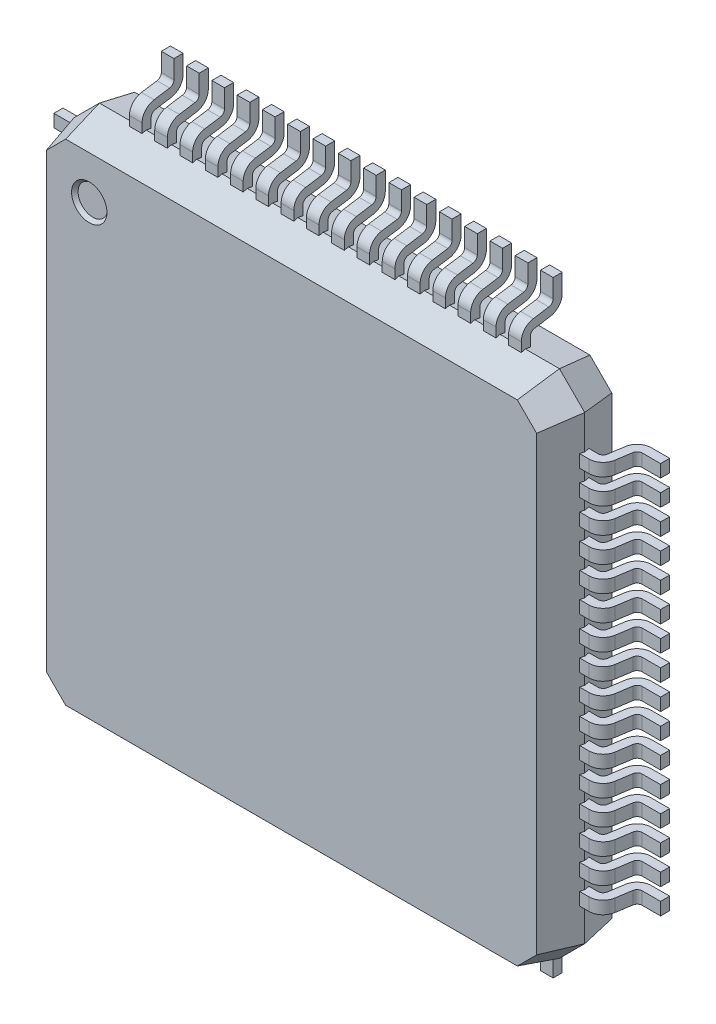
from build123d import *

# Parameters (mm, degrees)
EXTRUDE_START                    = 0.75
EXTRUDE_1_DEPTH                  = 0.75
EXTRUDE_1_TAPER                  = 15
EXTRUDE_1_OTHER_WAY_DEPTH        = 0.65
EXTRUDE_1_OTHER_WAY_TAPER        = 10
EXTRUDE_START_2                  = 3.875
EXTRUDE_2_DEPTH                  = 0.25
EXTRUDE_2_2_DEPTH                = 0.25
SKETCH_2_R                       = 0.35
CUT_EXTRUDE_3_DEPTH              = 0.07
CUT_EXTRUDE_3_TAPER              = 40
PATTERN_LINEAR_1_COUNT           = 16
PATTERN_LINEAR_1_PITCH           = 0.5
PATTERN_CIRCULAR_1_COUNT         = 2
PATTERN_CIRCULAR_1_ANGLE         = 90
PATTERN_START                    = 3.875
PATTERN_CIRCULAR_1_COPY_1_DEPTH  = 0.25
PATTERN_CIRCULAR_1_COPY_2_DEPTH  = 0.25
PATTERN_CIRCULAR_1_COPY_3_DEPTH  = 0.25
PATTERN_CIRCULAR_1_COPY_4_DEPTH  = 0.25
PATTERN_CIRCULAR_1_COPY_5_DEPTH  = 0.25
PATTERN_CIRCULAR_1_COPY_6_DEPTH  = 0.25
PATTERN_CIRCULAR_1_COPY_7_DEPTH  = 0.25
PATTERN_CIRCULAR_1_COPY_8_DEPTH  = 0.25
PATTERN_CIRCULAR_1_COPY_9_DEPTH  = 0.25
PATTERN_CIRCULAR_1_COPY_10_DEPTH = 0.25
PATTERN_CIRCULAR_1_COPY_11_DEPTH = 0.25
PATTERN_CIRCULAR_1_COPY_12_DEPTH = 0.25
PATTERN_CIRCULAR_1_COPY_13_DEPTH = 0.25
PATTERN_CIRCULAR_1_COPY_14_DEPTH = 0.25
PATTERN_CIRCULAR_1_COPY_15_DEPTH = 0.25
PATTERN_CIRCULAR_1_COPY_16_DEPTH = 0.25
PATTERN_CIRCULAR_1_COPY_17_DEPTH = 0.25
PATTERN_CIRCULAR_1_COPY_18_DEPTH = 0.25
PATTERN_CIRCULAR_1_COPY_19_DEPTH = 0.25
PATTERN_CIRCULAR_1_COPY_20_DEPTH = 0.25
PATTERN_CIRCULAR_1_COPY_21_DEPTH = 0.25
PATTERN_CIRCULAR_1_COPY_22_DEPTH = 0.25
PATTERN_CIRCULAR_1_COPY_23_DEPTH = 0.25
PATTERN_CIRCULAR_1_COPY_24_DEPTH = 0.25
PATTERN_CIRCULAR_1_COPY_25_DEPTH = 0.25
PATTERN_CIRCULAR_1_COPY_26_DEPTH = 0.25
PATTERN_CIRCULAR_1_COPY_27_DEPTH = 0.25
PATTERN_CIRCULAR_1_COPY_28_DEPTH = 0.25
PATTERN_CIRCULAR_1_COPY_29_DEPTH = 0.25
PATTERN_CIRCULAR_1_COPY_30_DEPTH = 0.25
PATTERN_CIRCULAR_1_COPY_31_DEPTH = 0.25


with BuildPart() as part:
    # Эскиз1 → Вытянуть1 (new body)
    with BuildSketch(Plane.XY.offset(EXTRUDE_START)):
        Polygon((-5.05, 4.55), (-5.05, -4.55), (-4.55, -5.05), (4.55, -5.05), (5.05, -4.55), (5.05, 4.55), (4.55, 5.05), (-4.55, 5.05), align=None)
    extrude(amount=EXTRUDE_1_DEPTH, taper=EXTRUDE_1_TAPER)

    # Эскиз1 → Вытянуть1 other way (add)
    with BuildSketch(Plane.XY.offset(EXTRUDE_START)):
        Polygon((-5.05, 4.55), (-5.05, -4.55), (-4.55, -5.05), (4.55, -5.05), (5.05, -4.55), (5.05, 4.55), (4.55, 5.05), (-4.55, 5.05), align=None)
    extrude(amount=-EXTRUDE_1_OTHER_WAY_DEPTH, taper=EXTRUDE_1_OTHER_WAY_TAPER)

    # Эскиз2 → Вытянуть3 (cut)
    with BuildSketch(Plane.XY.offset(1.5)):
        with Locations((-4, 4)):
            Circle(SKETCH_2_R)
    extrude(amount=-CUT_EXTRUDE_3_DEPTH, taper=CUT_EXTRUDE_3_TAPER, mode=Mode.SUBTRACT)


with BuildPart() as body_2:
    # Эскиз3 → Вытянуть2 (new body)
    with BuildSketch(Plane(origin=(0, 0, 0), x_dir=(1, 0, 0), z_dir=(0, 1, 0)).offset(EXTRUDE_START_2)):
        with BuildLine():
            Line((5.312679102, -0.565607799), (5.360345878, -0.257227898))
            ThreePointArc((5.360345878, -0.257227898), (5.454818375, -0.087425086), (5.637059714, -0.02))
            Line((5.637059714, -0.02), (6, -0.02))
            Line((6, -0.02), (6, -0.2))
            Line((6, -0.2), (5.637059714, -0.2))
            ThreePointArc((5.637059714, -0.2), (5.571973522, -0.224080388), (5.538233344, -0.284724249))
            Line((5.538233344, -0.284724249), (5.490566568, -0.59310415))
            ThreePointArc((5.490566568, -0.59310415), (5.396094071, -0.762906963), (5.213852732, -0.830332049))
            Line((5.213852732, -0.830332049), (4.985246956, -0.830332049))
            Line((4.985246956, -0.830332049), (4.985246956, -0.650332049))
            Line((4.985246956, -0.650332049), (5.213852732, -0.650332049))
            ThreePointArc((5.213852732, -0.650332049), (5.278938924, -0.626251661), (5.312679102, -0.565607799))
        make_face()
    extrude_2 = extrude(amount=-EXTRUDE_2_DEPTH)


with BuildPart() as body_3:
    # Эскиз3 → Extrude 2 2 (new body)
    with BuildSketch(Plane(origin=(0, 0, 0), x_dir=(1, 0, 0), z_dir=(0, 1, 0)).offset(EXTRUDE_START_2)):
        with BuildLine():
            Line((-4.985246956, -0.650332049), (-5.213852732, -0.650332049))
            ThreePointArc((-5.213852732, -0.650332049), (-5.278938924, -0.626251661), (-5.312679102, -0.565607799))
            Line((-5.312679102, -0.565607799), (-5.360345878, -0.257227898))
            ThreePointArc((-5.360345878, -0.257227898), (-5.454818375, -0.087425086), (-5.637059714, -0.02))
            Line((-5.637059714, -0.02), (-6, -0.02))
            Line((-6, -0.02), (-6, -0.2))
            Line((-6, -0.2), (-5.637059714, -0.2))
            ThreePointArc((-5.637059714, -0.2), (-5.571973522, -0.224080388), (-5.538233344, -0.284724249))
            Line((-5.538233344, -0.284724249), (-5.490566568, -0.59310415))
            ThreePointArc((-5.490566568, -0.59310415), (-5.396094071, -0.762906963), (-5.213852732, -0.830332049))
            Line((-5.213852732, -0.830332049), (-4.985246956, -0.830332049))
            Line((-4.985246956, -0.830332049), (-4.985246956, -0.650332049))
        make_face()
    extrude_2_2 = extrude(amount=-EXTRUDE_2_2_DEPTH)


with BuildPart() as part_1:
    add(part.part)

    # Линейный массив1: Вытянуть2, Extrude 2 2 ×16
    with Locations(*[(0, -i * PATTERN_LINEAR_1_PITCH, 0) for i in range(1, PATTERN_LINEAR_1_COUNT)]):
        add(extrude_2)
        add(extrude_2_2)

    # Круговой массив1: Вытянуть2, Extrude 2 2 ×2 about axis
    pattern_circular_1_axis = Axis((0, 0, 0), (0, 0, -1))
    for i in range(1, PATTERN_CIRCULAR_1_COUNT):
        add(extrude_2.rotate(pattern_circular_1_axis, i * PATTERN_CIRCULAR_1_ANGLE / (PATTERN_CIRCULAR_1_COUNT - 1)))
        add(extrude_2_2.rotate(pattern_circular_1_axis, i * PATTERN_CIRCULAR_1_ANGLE / (PATTERN_CIRCULAR_1_COUNT - 1)))

    # Круговой массив1 copy 1 sketch → Круговой массив1 copy 1 (add)
    with BuildSketch(Plane(origin=(-0.5, 0, 0), x_dir=(0, -1, 0), z_dir=(1, 0, 0)).offset(PATTERN_START)):
        with BuildLine():
            Line((5.312679102, -0.565607799), (5.360345878, -0.257227898))
            ThreePointArc((5.360345878, -0.257227898), (5.454818375, -0.087425086), (5.637059714, -0.02))
            Line((5.637059714, -0.02), (6, -0.02))
            Line((6, -0.02), (6, -0.2))
            Line((6, -0.2), (5.637059714, -0.2))
            ThreePointArc((5.637059714, -0.2), (5.571973522, -0.224080388), (5.538233344, -0.284724249))
            Line((5.538233344, -0.284724249), (5.490566568, -0.59310415))
            ThreePointArc((5.490566568, -0.59310415), (5.396094071, -0.762906963), (5.213852732, -0.830332049))
            Line((5.213852732, -0.830332049), (4.985246956, -0.830332049))
            Line((4.985246956, -0.830332049), (4.985246956, -0.650332049))
            Line((4.985246956, -0.650332049), (5.213852732, -0.650332049))
            ThreePointArc((5.213852732, -0.650332049), (5.278938924, -0.626251661), (5.312679102, -0.565607799))
        make_face()
    extrude(amount=-PATTERN_CIRCULAR_1_COPY_1_DEPTH)

    # Круговой массив1 copy 2 sketch → Круговой массив1 copy 2 (add)
    with BuildSketch(Plane(origin=(-1, 0, 0), x_dir=(0, -1, 0), z_dir=(1, 0, 0)).offset(PATTERN_START)):
        with BuildLine():
            Line((5.312679102, -0.565607799), (5.360345878, -0.257227898))
            ThreePointArc((5.360345878, -0.257227898), (5.454818375, -0.087425086), (5.637059714, -0.02))
            Line((5.637059714, -0.02), (6, -0.02))
            Line((6, -0.02), (6, -0.2))
            Line((6, -0.2), (5.637059714, -0.2))
            ThreePointArc((5.637059714, -0.2), (5.571973522, -0.224080388), (5.538233344, -0.284724249))
            Line((5.538233344, -0.284724249), (5.490566568, -0.59310415))
            ThreePointArc((5.490566568, -0.59310415), (5.396094071, -0.762906963), (5.213852732, -0.830332049))
            Line((5.213852732, -0.830332049), (4.985246956, -0.830332049))
            Line((4.985246956, -0.830332049), (4.985246956, -0.650332049))
            Line((4.985246956, -0.650332049), (5.213852732, -0.650332049))
            ThreePointArc((5.213852732, -0.650332049), (5.278938924, -0.626251661), (5.312679102, -0.565607799))
        make_face()
    extrude(amount=-PATTERN_CIRCULAR_1_COPY_2_DEPTH)

    # Круговой массив1 copy 3 sketch → Круговой массив1 copy 3 (add)
    with BuildSketch(Plane(origin=(-1.5, 0, 0), x_dir=(0, -1, 0), z_dir=(1, 0, 0)).offset(PATTERN_START)):
        with BuildLine():
            Line((5.312679102, -0.565607799), (5.360345878, -0.257227898))
            ThreePointArc((5.360345878, -0.257227898), (5.454818375, -0.087425086), (5.637059714, -0.02))
            Line((5.637059714, -0.02), (6, -0.02))
            Line((6, -0.02), (6, -0.2))
            Line((6, -0.2), (5.637059714, -0.2))
            ThreePointArc((5.637059714, -0.2), (5.571973522, -0.224080388), (5.538233344, -0.284724249))
            Line((5.538233344, -0.284724249), (5.490566568, -0.59310415))
            ThreePointArc((5.490566568, -0.59310415), (5.396094071, -0.762906963), (5.213852732, -0.830332049))
            Line((5.213852732, -0.830332049), (4.985246956, -0.830332049))
            Line((4.985246956, -0.830332049), (4.985246956, -0.650332049))
            Line((4.985246956, -0.650332049), (5.213852732, -0.650332049))
            ThreePointArc((5.213852732, -0.650332049), (5.278938924, -0.626251661), (5.312679102, -0.565607799))
        make_face()
    extrude(amount=-PATTERN_CIRCULAR_1_COPY_3_DEPTH)

    # Круговой массив1 copy 4 sketch → Круговой массив1 copy 4 (add)
    with BuildSketch(Plane(origin=(-2, 0, 0), x_dir=(0, -1, 0), z_dir=(1, 0, 0)).offset(PATTERN_START)):
        with BuildLine():
            Line((5.312679102, -0.565607799), (5.360345878, -0.257227898))
            ThreePointArc((5.360345878, -0.257227898), (5.454818375, -0.087425086), (5.637059714, -0.02))
            Line((5.637059714, -0.02), (6, -0.02))
            Line((6, -0.02), (6, -0.2))
            Line((6, -0.2), (5.637059714, -0.2))
            ThreePointArc((5.637059714, -0.2), (5.571973522, -0.224080388), (5.538233344, -0.284724249))
            Line((5.538233344, -0.284724249), (5.490566568, -0.59310415))
            ThreePointArc((5.490566568, -0.59310415), (5.396094071, -0.762906963), (5.213852732, -0.830332049))
            Line((5.213852732, -0.830332049), (4.985246956, -0.830332049))
            Line((4.985246956, -0.830332049), (4.985246956, -0.650332049))
            Line((4.985246956, -0.650332049), (5.213852732, -0.650332049))
            ThreePointArc((5.213852732, -0.650332049), (5.278938924, -0.626251661), (5.312679102, -0.565607799))
        make_face()
    extrude(amount=-PATTERN_CIRCULAR_1_COPY_4_DEPTH)

    # Круговой массив1 copy 5 sketch → Круговой массив1 copy 5 (add)
    with BuildSketch(Plane(origin=(-2.5, 0, 0), x_dir=(0, -1, 0), z_dir=(1, 0, 0)).offset(PATTERN_START)):
        with BuildLine():
            Line((5.312679102, -0.565607799), (5.360345878, -0.257227898))
            ThreePointArc((5.360345878, -0.257227898), (5.454818375, -0.087425086), (5.637059714, -0.02))
            Line((5.637059714, -0.02), (6, -0.02))
            Line((6, -0.02), (6, -0.2))
            Line((6, -0.2), (5.637059714, -0.2))
            ThreePointArc((5.637059714, -0.2), (5.571973522, -0.224080388), (5.538233344, -0.284724249))
            Line((5.538233344, -0.284724249), (5.490566568, -0.59310415))
            ThreePointArc((5.490566568, -0.59310415), (5.396094071, -0.762906963), (5.213852732, -0.830332049))
            Line((5.213852732, -0.830332049), (4.985246956, -0.830332049))
            Line((4.985246956, -0.830332049), (4.985246956, -0.650332049))
            Line((4.985246956, -0.650332049), (5.213852732, -0.650332049))
            ThreePointArc((5.213852732, -0.650332049), (5.278938924, -0.626251661), (5.312679102, -0.565607799))
        make_face()
    extrude(amount=-PATTERN_CIRCULAR_1_COPY_5_DEPTH)

    # Круговой массив1 copy 6 sketch → Круговой массив1 copy 6 (add)
    with BuildSketch(Plane(origin=(-3, 0, 0), x_dir=(0, -1, 0), z_dir=(1, 0, 0)).offset(PATTERN_START)):
        with BuildLine():
            Line((5.312679102, -0.565607799), (5.360345878, -0.257227898))
            ThreePointArc((5.360345878, -0.257227898), (5.454818375, -0.087425086), (5.637059714, -0.02))
            Line((5.637059714, -0.02), (6, -0.02))
            Line((6, -0.02), (6, -0.2))
            Line((6, -0.2), (5.637059714, -0.2))
            ThreePointArc((5.637059714, -0.2), (5.571973522, -0.224080388), (5.538233344, -0.284724249))
            Line((5.538233344, -0.284724249), (5.490566568, -0.59310415))
            ThreePointArc((5.490566568, -0.59310415), (5.396094071, -0.762906963), (5.213852732, -0.830332049))
            Line((5.213852732, -0.830332049), (4.985246956, -0.830332049))
            Line((4.985246956, -0.830332049), (4.985246956, -0.650332049))
            Line((4.985246956, -0.650332049), (5.213852732, -0.650332049))
            ThreePointArc((5.213852732, -0.650332049), (5.278938924, -0.626251661), (5.312679102, -0.565607799))
        make_face()
    extrude(amount=-PATTERN_CIRCULAR_1_COPY_6_DEPTH)

    # Круговой массив1 copy 7 sketch → Круговой массив1 copy 7 (add)
    with BuildSketch(Plane(origin=(-3.5, 0, 0), x_dir=(0, -1, 0), z_dir=(1, 0, 0)).offset(PATTERN_START)):
        with BuildLine():
            Line((5.312679102, -0.565607799), (5.360345878, -0.257227898))
            ThreePointArc((5.360345878, -0.257227898), (5.454818375, -0.087425086), (5.637059714, -0.02))
            Line((5.637059714, -0.02), (6, -0.02))
            Line((6, -0.02), (6, -0.2))
            Line((6, -0.2), (5.637059714, -0.2))
            ThreePointArc((5.637059714, -0.2), (5.571973522, -0.224080388), (5.538233344, -0.284724249))
            Line((5.538233344, -0.284724249), (5.490566568, -0.59310415))
            ThreePointArc((5.490566568, -0.59310415), (5.396094071, -0.762906963), (5.213852732, -0.830332049))
            Line((5.213852732, -0.830332049), (4.985246956, -0.830332049))
            Line((4.985246956, -0.830332049), (4.985246956, -0.650332049))
            Line((4.985246956, -0.650332049), (5.213852732, -0.650332049))
            ThreePointArc((5.213852732, -0.650332049), (5.278938924, -0.626251661), (5.312679102, -0.565607799))
        make_face()
    extrude(amount=-PATTERN_CIRCULAR_1_COPY_7_DEPTH)

    # Круговой массив1 copy 8 sketch → Круговой массив1 copy 8 (add)
    with BuildSketch(Plane(origin=(-4, 0, 0), x_dir=(0, -1, 0), z_dir=(1, 0, 0)).offset(PATTERN_START)):
        with BuildLine():
            Line((5.312679102, -0.565607799), (5.360345878, -0.257227898))
            ThreePointArc((5.360345878, -0.257227898), (5.454818375, -0.087425086), (5.637059714, -0.02))
            Line((5.637059714, -0.02), (6, -0.02))
            Line((6, -0.02), (6, -0.2))
            Line((6, -0.2), (5.637059714, -0.2))
            ThreePointArc((5.637059714, -0.2), (5.571973522, -0.224080388), (5.538233344, -0.284724249))
            Line((5.538233344, -0.284724249), (5.490566568, -0.59310415))
            ThreePointArc((5.490566568, -0.59310415), (5.396094071, -0.762906963), (5.213852732, -0.830332049))
            Line((5.213852732, -0.830332049), (4.985246956, -0.830332049))
            Line((4.985246956, -0.830332049), (4.985246956, -0.650332049))
            Line((4.985246956, -0.650332049), (5.213852732, -0.650332049))
            ThreePointArc((5.213852732, -0.650332049), (5.278938924, -0.626251661), (5.312679102, -0.565607799))
        make_face()
    extrude(amount=-PATTERN_CIRCULAR_1_COPY_8_DEPTH)

    # Круговой массив1 copy 9 sketch → Круговой массив1 copy 9 (add)
    with BuildSketch(Plane(origin=(-4.5, 0, 0), x_dir=(0, -1, 0), z_dir=(1, 0, 0)).offset(PATTERN_START)):
        with BuildLine():
            Line((5.312679102, -0.565607799), (5.360345878, -0.257227898))
            ThreePointArc((5.360345878, -0.257227898), (5.454818375, -0.087425086), (5.637059714, -0.02))
            Line((5.637059714, -0.02), (6, -0.02))
            Line((6, -0.02), (6, -0.2))
            Line((6, -0.2), (5.637059714, -0.2))
            ThreePointArc((5.637059714, -0.2), (5.571973522, -0.224080388), (5.538233344, -0.284724249))
            Line((5.538233344, -0.284724249), (5.490566568, -0.59310415))
            ThreePointArc((5.490566568, -0.59310415), (5.396094071, -0.762906963), (5.213852732, -0.830332049))
            Line((5.213852732, -0.830332049), (4.985246956, -0.830332049))
            Line((4.985246956, -0.830332049), (4.985246956, -0.650332049))
            Line((4.985246956, -0.650332049), (5.213852732, -0.650332049))
            ThreePointArc((5.213852732, -0.650332049), (5.278938924, -0.626251661), (5.312679102, -0.565607799))
        make_face()
    extrude(amount=-PATTERN_CIRCULAR_1_COPY_9_DEPTH)

    # Круговой массив1 copy 10 sketch → Круговой массив1 copy 10 (add)
    with BuildSketch(Plane(origin=(-5, 0, 0), x_dir=(0, -1, 0), z_dir=(1, 0, 0)).offset(PATTERN_START)):
        with BuildLine():
            Line((5.312679102, -0.565607799), (5.360345878, -0.257227898))
            ThreePointArc((5.360345878, -0.257227898), (5.454818375, -0.087425086), (5.637059714, -0.02))
            Line((5.637059714, -0.02), (6, -0.02))
            Line((6, -0.02), (6, -0.2))
            Line((6, -0.2), (5.637059714, -0.2))
            ThreePointArc((5.637059714, -0.2), (5.571973522, -0.224080388), (5.538233344, -0.284724249))
            Line((5.538233344, -0.284724249), (5.490566568, -0.59310415))
            ThreePointArc((5.490566568, -0.59310415), (5.396094071, -0.762906963), (5.213852732, -0.830332049))
            Line((5.213852732, -0.830332049), (4.985246956, -0.830332049))
            Line((4.985246956, -0.830332049), (4.985246956, -0.650332049))
            Line((4.985246956, -0.650332049), (5.213852732, -0.650332049))
            ThreePointArc((5.213852732, -0.650332049), (5.278938924, -0.626251661), (5.312679102, -0.565607799))
        make_face()
    extrude(amount=-PATTERN_CIRCULAR_1_COPY_10_DEPTH)

    # Круговой массив1 copy 11 sketch → Круговой массив1 copy 11 (add)
    with BuildSketch(Plane(origin=(-5.5, 0, 0), x_dir=(0, -1, 0), z_dir=(1, 0, 0)).offset(PATTERN_START)):
        with BuildLine():
            Line((5.312679102, -0.565607799), (5.360345878, -0.257227898))
            ThreePointArc((5.360345878, -0.257227898), (5.454818375, -0.087425086), (5.637059714, -0.02))
            Line((5.637059714, -0.02), (6, -0.02))
            Line((6, -0.02), (6, -0.2))
            Line((6, -0.2), (5.637059714, -0.2))
            ThreePointArc((5.637059714, -0.2), (5.571973522, -0.224080388), (5.538233344, -0.284724249))
            Line((5.538233344, -0.284724249), (5.490566568, -0.59310415))
            ThreePointArc((5.490566568, -0.59310415), (5.396094071, -0.762906963), (5.213852732, -0.830332049))
            Line((5.213852732, -0.830332049), (4.985246956, -0.830332049))
            Line((4.985246956, -0.830332049), (4.985246956, -0.650332049))
            Line((4.985246956, -0.650332049), (5.213852732, -0.650332049))
            ThreePointArc((5.213852732, -0.650332049), (5.278938924, -0.626251661), (5.312679102, -0.565607799))
        make_face()
    extrude(amount=-PATTERN_CIRCULAR_1_COPY_11_DEPTH)

    # Круговой массив1 copy 12 sketch → Круговой массив1 copy 12 (add)
    with BuildSketch(Plane(origin=(-6, 0, 0), x_dir=(0, -1, 0), z_dir=(1, 0, 0)).offset(PATTERN_START)):
        with BuildLine():
            Line((5.312679102, -0.565607799), (5.360345878, -0.257227898))
            ThreePointArc((5.360345878, -0.257227898), (5.454818375, -0.087425086), (5.637059714, -0.02))
            Line((5.637059714, -0.02), (6, -0.02))
            Line((6, -0.02), (6, -0.2))
            Line((6, -0.2), (5.637059714, -0.2))
            ThreePointArc((5.637059714, -0.2), (5.571973522, -0.224080388), (5.538233344, -0.284724249))
            Line((5.538233344, -0.284724249), (5.490566568, -0.59310415))
            ThreePointArc((5.490566568, -0.59310415), (5.396094071, -0.762906963), (5.213852732, -0.830332049))
            Line((5.213852732, -0.830332049), (4.985246956, -0.830332049))
            Line((4.985246956, -0.830332049), (4.985246956, -0.650332049))
            Line((4.985246956, -0.650332049), (5.213852732, -0.650332049))
            ThreePointArc((5.213852732, -0.650332049), (5.278938924, -0.626251661), (5.312679102, -0.565607799))
        make_face()
    extrude(amount=-PATTERN_CIRCULAR_1_COPY_12_DEPTH)

    # Круговой массив1 copy 13 sketch → Круговой массив1 copy 13 (add)
    with BuildSketch(Plane(origin=(-6.5, 0, 0), x_dir=(0, -1, 0), z_dir=(1, 0, 0)).offset(PATTERN_START)):
        with BuildLine():
            Line((5.312679102, -0.565607799), (5.360345878, -0.257227898))
            ThreePointArc((5.360345878, -0.257227898), (5.454818375, -0.087425086), (5.637059714, -0.02))
            Line((5.637059714, -0.02), (6, -0.02))
            Line((6, -0.02), (6, -0.2))
            Line((6, -0.2), (5.637059714, -0.2))
            ThreePointArc((5.637059714, -0.2), (5.571973522, -0.224080388), (5.538233344, -0.284724249))
            Line((5.538233344, -0.284724249), (5.490566568, -0.59310415))
            ThreePointArc((5.490566568, -0.59310415), (5.396094071, -0.762906963), (5.213852732, -0.830332049))
            Line((5.213852732, -0.830332049), (4.985246956, -0.830332049))
            Line((4.985246956, -0.830332049), (4.985246956, -0.650332049))
            Line((4.985246956, -0.650332049), (5.213852732, -0.650332049))
            ThreePointArc((5.213852732, -0.650332049), (5.278938924, -0.626251661), (5.312679102, -0.565607799))
        make_face()
    extrude(amount=-PATTERN_CIRCULAR_1_COPY_13_DEPTH)

    # Круговой массив1 copy 14 sketch → Круговой массив1 copy 14 (add)
    with BuildSketch(Plane(origin=(-7, 0, 0), x_dir=(0, -1, 0), z_dir=(1, 0, 0)).offset(PATTERN_START)):
        with BuildLine():
            Line((5.312679102, -0.565607799), (5.360345878, -0.257227898))
            ThreePointArc((5.360345878, -0.257227898), (5.454818375, -0.087425086), (5.637059714, -0.02))
            Line((5.637059714, -0.02), (6, -0.02))
            Line((6, -0.02), (6, -0.2))
            Line((6, -0.2), (5.637059714, -0.2))
            ThreePointArc((5.637059714, -0.2), (5.571973522, -0.224080388), (5.538233344, -0.284724249))
            Line((5.538233344, -0.284724249), (5.490566568, -0.59310415))
            ThreePointArc((5.490566568, -0.59310415), (5.396094071, -0.762906963), (5.213852732, -0.830332049))
            Line((5.213852732, -0.830332049), (4.985246956, -0.830332049))
            Line((4.985246956, -0.830332049), (4.985246956, -0.650332049))
            Line((4.985246956, -0.650332049), (5.213852732, -0.650332049))
            ThreePointArc((5.213852732, -0.650332049), (5.278938924, -0.626251661), (5.312679102, -0.565607799))
        make_face()
    extrude(amount=-PATTERN_CIRCULAR_1_COPY_14_DEPTH)

    # Круговой массив1 copy 15 sketch → Круговой массив1 copy 15 (add)
    with BuildSketch(Plane(origin=(-7.5, 0, 0), x_dir=(0, -1, 0), z_dir=(1, 0, 0)).offset(PATTERN_START)):
        with BuildLine():
            Line((5.312679102, -0.565607799), (5.360345878, -0.257227898))
            ThreePointArc((5.360345878, -0.257227898), (5.454818375, -0.087425086), (5.637059714, -0.02))
            Line((5.637059714, -0.02), (6, -0.02))
            Line((6, -0.02), (6, -0.2))
            Line((6, -0.2), (5.637059714, -0.2))
            ThreePointArc((5.637059714, -0.2), (5.571973522, -0.224080388), (5.538233344, -0.284724249))
            Line((5.538233344, -0.284724249), (5.490566568, -0.59310415))
            ThreePointArc((5.490566568, -0.59310415), (5.396094071, -0.762906963), (5.213852732, -0.830332049))
            Line((5.213852732, -0.830332049), (4.985246956, -0.830332049))
            Line((4.985246956, -0.830332049), (4.985246956, -0.650332049))
            Line((4.985246956, -0.650332049), (5.213852732, -0.650332049))
            ThreePointArc((5.213852732, -0.650332049), (5.278938924, -0.626251661), (5.312679102, -0.565607799))
        make_face()
    extrude(amount=-PATTERN_CIRCULAR_1_COPY_15_DEPTH)

    # Круговой массив1 copy 16 sketch → Круговой массив1 copy 16 (add)
    with BuildSketch(Plane(origin=(-0.5, 0, 0), x_dir=(0, -1, 0), z_dir=(1, 0, 0)).offset(PATTERN_START)):
        with BuildLine():
            Line((-4.985246956, -0.650332049), (-5.213852732, -0.650332049))
            ThreePointArc((-5.213852732, -0.650332049), (-5.278938924, -0.626251661), (-5.312679102, -0.565607799))
            Line((-5.312679102, -0.565607799), (-5.360345878, -0.257227898))
            ThreePointArc((-5.360345878, -0.257227898), (-5.454818375, -0.087425086), (-5.637059714, -0.02))
            Line((-5.637059714, -0.02), (-6, -0.02))
            Line((-6, -0.02), (-6, -0.2))
            Line((-6, -0.2), (-5.637059714, -0.2))
            ThreePointArc((-5.637059714, -0.2), (-5.571973522, -0.224080388), (-5.538233344, -0.284724249))
            Line((-5.538233344, -0.284724249), (-5.490566568, -0.59310415))
            ThreePointArc((-5.490566568, -0.59310415), (-5.396094071, -0.762906963), (-5.213852732, -0.830332049))
            Line((-5.213852732, -0.830332049), (-4.985246956, -0.830332049))
            Line((-4.985246956, -0.830332049), (-4.985246956, -0.650332049))
        make_face()
    extrude(amount=-PATTERN_CIRCULAR_1_COPY_16_DEPTH)

    # Круговой массив1 copy 17 sketch → Круговой массив1 copy 17 (add)
    with BuildSketch(Plane(origin=(-1, 0, 0), x_dir=(0, -1, 0), z_dir=(1, 0, 0)).offset(PATTERN_START)):
        with BuildLine():
            Line((-4.985246956, -0.650332049), (-5.213852732, -0.650332049))
            ThreePointArc((-5.213852732, -0.650332049), (-5.278938924, -0.626251661), (-5.312679102, -0.565607799))
            Line((-5.312679102, -0.565607799), (-5.360345878, -0.257227898))
            ThreePointArc((-5.360345878, -0.257227898), (-5.454818375, -0.087425086), (-5.637059714, -0.02))
            Line((-5.637059714, -0.02), (-6, -0.02))
            Line((-6, -0.02), (-6, -0.2))
            Line((-6, -0.2), (-5.637059714, -0.2))
            ThreePointArc((-5.637059714, -0.2), (-5.571973522, -0.224080388), (-5.538233344, -0.284724249))
            Line((-5.538233344, -0.284724249), (-5.490566568, -0.59310415))
            ThreePointArc((-5.490566568, -0.59310415), (-5.396094071, -0.762906963), (-5.213852732, -0.830332049))
            Line((-5.213852732, -0.830332049), (-4.985246956, -0.830332049))
            Line((-4.985246956, -0.830332049), (-4.985246956, -0.650332049))
        make_face()
    extrude(amount=-PATTERN_CIRCULAR_1_COPY_17_DEPTH)

    # Круговой массив1 copy 18 sketch → Круговой массив1 copy 18 (add)
    with BuildSketch(Plane(origin=(-1.5, 0, 0), x_dir=(0, -1, 0), z_dir=(1, 0, 0)).offset(PATTERN_START)):
        with BuildLine():
            Line((-4.985246956, -0.650332049), (-5.213852732, -0.650332049))
            ThreePointArc((-5.213852732, -0.650332049), (-5.278938924, -0.626251661), (-5.312679102, -0.565607799))
            Line((-5.312679102, -0.565607799), (-5.360345878, -0.257227898))
            ThreePointArc((-5.360345878, -0.257227898), (-5.454818375, -0.087425086), (-5.637059714, -0.02))
            Line((-5.637059714, -0.02), (-6, -0.02))
            Line((-6, -0.02), (-6, -0.2))
            Line((-6, -0.2), (-5.637059714, -0.2))
            ThreePointArc((-5.637059714, -0.2), (-5.571973522, -0.224080388), (-5.538233344, -0.284724249))
            Line((-5.538233344, -0.284724249), (-5.490566568, -0.59310415))
            ThreePointArc((-5.490566568, -0.59310415), (-5.396094071, -0.762906963), (-5.213852732, -0.830332049))
            Line((-5.213852732, -0.830332049), (-4.985246956, -0.830332049))
            Line((-4.985246956, -0.830332049), (-4.985246956, -0.650332049))
        make_face()
    extrude(amount=-PATTERN_CIRCULAR_1_COPY_18_DEPTH)

    # Круговой массив1 copy 19 sketch → Круговой массив1 copy 19 (add)
    with BuildSketch(Plane(origin=(-2, 0, 0), x_dir=(0, -1, 0), z_dir=(1, 0, 0)).offset(PATTERN_START)):
        with BuildLine():
            Line((-4.985246956, -0.650332049), (-5.213852732, -0.650332049))
            ThreePointArc((-5.213852732, -0.650332049), (-5.278938924, -0.626251661), (-5.312679102, -0.565607799))
            Line((-5.312679102, -0.565607799), (-5.360345878, -0.257227898))
            ThreePointArc((-5.360345878, -0.257227898), (-5.454818375, -0.087425086), (-5.637059714, -0.02))
            Line((-5.637059714, -0.02), (-6, -0.02))
            Line((-6, -0.02), (-6, -0.2))
            Line((-6, -0.2), (-5.637059714, -0.2))
            ThreePointArc((-5.637059714, -0.2), (-5.571973522, -0.224080388), (-5.538233344, -0.284724249))
            Line((-5.538233344, -0.284724249), (-5.490566568, -0.59310415))
            ThreePointArc((-5.490566568, -0.59310415), (-5.396094071, -0.762906963), (-5.213852732, -0.830332049))
            Line((-5.213852732, -0.830332049), (-4.985246956, -0.830332049))
            Line((-4.985246956, -0.830332049), (-4.985246956, -0.650332049))
        make_face()
    extrude(amount=-PATTERN_CIRCULAR_1_COPY_19_DEPTH)

    # Круговой массив1 copy 20 sketch → Круговой массив1 copy 20 (add)
    with BuildSketch(Plane(origin=(-2.5, 0, 0), x_dir=(0, -1, 0), z_dir=(1, 0, 0)).offset(PATTERN_START)):
        with BuildLine():
            Line((-4.985246956, -0.650332049), (-5.213852732, -0.650332049))
            ThreePointArc((-5.213852732, -0.650332049), (-5.278938924, -0.626251661), (-5.312679102, -0.565607799))
            Line((-5.312679102, -0.565607799), (-5.360345878, -0.257227898))
            ThreePointArc((-5.360345878, -0.257227898), (-5.454818375, -0.087425086), (-5.637059714, -0.02))
            Line((-5.637059714, -0.02), (-6, -0.02))
            Line((-6, -0.02), (-6, -0.2))
            Line((-6, -0.2), (-5.637059714, -0.2))
            ThreePointArc((-5.637059714, -0.2), (-5.571973522, -0.224080388), (-5.538233344, -0.284724249))
            Line((-5.538233344, -0.284724249), (-5.490566568, -0.59310415))
            ThreePointArc((-5.490566568, -0.59310415), (-5.396094071, -0.762906963), (-5.213852732, -0.830332049))
            Line((-5.213852732, -0.830332049), (-4.985246956, -0.830332049))
            Line((-4.985246956, -0.830332049), (-4.985246956, -0.650332049))
        make_face()
    extrude(amount=-PATTERN_CIRCULAR_1_COPY_20_DEPTH)

    # Круговой массив1 copy 21 sketch → Круговой массив1 copy 21 (add)
    with BuildSketch(Plane(origin=(-3, 0, 0), x_dir=(0, -1, 0), z_dir=(1, 0, 0)).offset(PATTERN_START)):
        with BuildLine():
            Line((-4.985246956, -0.650332049), (-5.213852732, -0.650332049))
            ThreePointArc((-5.213852732, -0.650332049), (-5.278938924, -0.626251661), (-5.312679102, -0.565607799))
            Line((-5.312679102, -0.565607799), (-5.360345878, -0.257227898))
            ThreePointArc((-5.360345878, -0.257227898), (-5.454818375, -0.087425086), (-5.637059714, -0.02))
            Line((-5.637059714, -0.02), (-6, -0.02))
            Line((-6, -0.02), (-6, -0.2))
            Line((-6, -0.2), (-5.637059714, -0.2))
            ThreePointArc((-5.637059714, -0.2), (-5.571973522, -0.224080388), (-5.538233344, -0.284724249))
            Line((-5.538233344, -0.284724249), (-5.490566568, -0.59310415))
            ThreePointArc((-5.490566568, -0.59310415), (-5.396094071, -0.762906963), (-5.213852732, -0.830332049))
            Line((-5.213852732, -0.830332049), (-4.985246956, -0.830332049))
            Line((-4.985246956, -0.830332049), (-4.985246956, -0.650332049))
        make_face()
    extrude(amount=-PATTERN_CIRCULAR_1_COPY_21_DEPTH)

    # Круговой массив1 copy 22 sketch → Круговой массив1 copy 22 (add)
    with BuildSketch(Plane(origin=(-3.5, 0, 0), x_dir=(0, -1, 0), z_dir=(1, 0, 0)).offset(PATTERN_START)):
        with BuildLine():
            Line((-4.985246956, -0.650332049), (-5.213852732, -0.650332049))
            ThreePointArc((-5.213852732, -0.650332049), (-5.278938924, -0.626251661), (-5.312679102, -0.565607799))
            Line((-5.312679102, -0.565607799), (-5.360345878, -0.257227898))
            ThreePointArc((-5.360345878, -0.257227898), (-5.454818375, -0.087425086), (-5.637059714, -0.02))
            Line((-5.637059714, -0.02), (-6, -0.02))
            Line((-6, -0.02), (-6, -0.2))
            Line((-6, -0.2), (-5.637059714, -0.2))
            ThreePointArc((-5.637059714, -0.2), (-5.571973522, -0.224080388), (-5.538233344, -0.284724249))
            Line((-5.538233344, -0.284724249), (-5.490566568, -0.59310415))
            ThreePointArc((-5.490566568, -0.59310415), (-5.396094071, -0.762906963), (-5.213852732, -0.830332049))
            Line((-5.213852732, -0.830332049), (-4.985246956, -0.830332049))
            Line((-4.985246956, -0.830332049), (-4.985246956, -0.650332049))
        make_face()
    extrude(amount=-PATTERN_CIRCULAR_1_COPY_22_DEPTH)

    # Круговой массив1 copy 23 sketch → Круговой массив1 copy 23 (add)
    with BuildSketch(Plane(origin=(-4, 0, 0), x_dir=(0, -1, 0), z_dir=(1, 0, 0)).offset(PATTERN_START)):
        with BuildLine():
            Line((-4.985246956, -0.650332049), (-5.213852732, -0.650332049))
            ThreePointArc((-5.213852732, -0.650332049), (-5.278938924, -0.626251661), (-5.312679102, -0.565607799))
            Line((-5.312679102, -0.565607799), (-5.360345878, -0.257227898))
            ThreePointArc((-5.360345878, -0.257227898), (-5.454818375, -0.087425086), (-5.637059714, -0.02))
            Line((-5.637059714, -0.02), (-6, -0.02))
            Line((-6, -0.02), (-6, -0.2))
            Line((-6, -0.2), (-5.637059714, -0.2))
            ThreePointArc((-5.637059714, -0.2), (-5.571973522, -0.224080388), (-5.538233344, -0.284724249))
            Line((-5.538233344, -0.284724249), (-5.490566568, -0.59310415))
            ThreePointArc((-5.490566568, -0.59310415), (-5.396094071, -0.762906963), (-5.213852732, -0.830332049))
            Line((-5.213852732, -0.830332049), (-4.985246956, -0.830332049))
            Line((-4.985246956, -0.830332049), (-4.985246956, -0.650332049))
        make_face()
    extrude(amount=-PATTERN_CIRCULAR_1_COPY_23_DEPTH)

    # Круговой массив1 copy 24 sketch → Круговой массив1 copy 24 (add)
    with BuildSketch(Plane(origin=(-4.5, 0, 0), x_dir=(0, -1, 0), z_dir=(1, 0, 0)).offset(PATTERN_START)):
        with BuildLine():
            Line((-4.985246956, -0.650332049), (-5.213852732, -0.650332049))
            ThreePointArc((-5.213852732, -0.650332049), (-5.278938924, -0.626251661), (-5.312679102, -0.565607799))
            Line((-5.312679102, -0.565607799), (-5.360345878, -0.257227898))
            ThreePointArc((-5.360345878, -0.257227898), (-5.454818375, -0.087425086), (-5.637059714, -0.02))
            Line((-5.637059714, -0.02), (-6, -0.02))
            Line((-6, -0.02), (-6, -0.2))
            Line((-6, -0.2), (-5.637059714, -0.2))
            ThreePointArc((-5.637059714, -0.2), (-5.571973522, -0.224080388), (-5.538233344, -0.284724249))
            Line((-5.538233344, -0.284724249), (-5.490566568, -0.59310415))
            ThreePointArc((-5.490566568, -0.59310415), (-5.396094071, -0.762906963), (-5.213852732, -0.830332049))
            Line((-5.213852732, -0.830332049), (-4.985246956, -0.830332049))
            Line((-4.985246956, -0.830332049), (-4.985246956, -0.650332049))
        make_face()
    extrude(amount=-PATTERN_CIRCULAR_1_COPY_24_DEPTH)

    # Круговой массив1 copy 25 sketch → Круговой массив1 copy 25 (add)
    with BuildSketch(Plane(origin=(-5, 0, 0), x_dir=(0, -1, 0), z_dir=(1, 0, 0)).offset(PATTERN_START)):
        with BuildLine():
            Line((-4.985246956, -0.650332049), (-5.213852732, -0.650332049))
            ThreePointArc((-5.213852732, -0.650332049), (-5.278938924, -0.626251661), (-5.312679102, -0.565607799))
            Line((-5.312679102, -0.565607799), (-5.360345878, -0.257227898))
            ThreePointArc((-5.360345878, -0.257227898), (-5.454818375, -0.087425086), (-5.637059714, -0.02))
            Line((-5.637059714, -0.02), (-6, -0.02))
            Line((-6, -0.02), (-6, -0.2))
            Line((-6, -0.2), (-5.637059714, -0.2))
            ThreePointArc((-5.637059714, -0.2), (-5.571973522, -0.224080388), (-5.538233344, -0.284724249))
            Line((-5.538233344, -0.284724249), (-5.490566568, -0.59310415))
            ThreePointArc((-5.490566568, -0.59310415), (-5.396094071, -0.762906963), (-5.213852732, -0.830332049))
            Line((-5.213852732, -0.830332049), (-4.985246956, -0.830332049))
            Line((-4.985246956, -0.830332049), (-4.985246956, -0.650332049))
        make_face()
    extrude(amount=-PATTERN_CIRCULAR_1_COPY_25_DEPTH)

    # Круговой массив1 copy 26 sketch → Круговой массив1 copy 26 (add)
    with BuildSketch(Plane(origin=(-5.5, 0, 0), x_dir=(0, -1, 0), z_dir=(1, 0, 0)).offset(PATTERN_START)):
        with BuildLine():
            Line((-4.985246956, -0.650332049), (-5.213852732, -0.650332049))
            ThreePointArc((-5.213852732, -0.650332049), (-5.278938924, -0.626251661), (-5.312679102, -0.565607799))
            Line((-5.312679102, -0.565607799), (-5.360345878, -0.257227898))
            ThreePointArc((-5.360345878, -0.257227898), (-5.454818375, -0.087425086), (-5.637059714, -0.02))
            Line((-5.637059714, -0.02), (-6, -0.02))
            Line((-6, -0.02), (-6, -0.2))
            Line((-6, -0.2), (-5.637059714, -0.2))
            ThreePointArc((-5.637059714, -0.2), (-5.571973522, -0.224080388), (-5.538233344, -0.284724249))
            Line((-5.538233344, -0.284724249), (-5.490566568, -0.59310415))
            ThreePointArc((-5.490566568, -0.59310415), (-5.396094071, -0.762906963), (-5.213852732, -0.830332049))
            Line((-5.213852732, -0.830332049), (-4.985246956, -0.830332049))
            Line((-4.985246956, -0.830332049), (-4.985246956, -0.650332049))
        make_face()
    extrude(amount=-PATTERN_CIRCULAR_1_COPY_26_DEPTH)

    # Круговой массив1 copy 27 sketch → Круговой массив1 copy 27 (add)
    with BuildSketch(Plane(origin=(-6, 0, 0), x_dir=(0, -1, 0), z_dir=(1, 0, 0)).offset(PATTERN_START)):
        with BuildLine():
            Line((-4.985246956, -0.650332049), (-5.213852732, -0.650332049))
            ThreePointArc((-5.213852732, -0.650332049), (-5.278938924, -0.626251661), (-5.312679102, -0.565607799))
            Line((-5.312679102, -0.565607799), (-5.360345878, -0.257227898))
            ThreePointArc((-5.360345878, -0.257227898), (-5.454818375, -0.087425086), (-5.637059714, -0.02))
            Line((-5.637059714, -0.02), (-6, -0.02))
            Line((-6, -0.02), (-6, -0.2))
            Line((-6, -0.2), (-5.637059714, -0.2))
            ThreePointArc((-5.637059714, -0.2), (-5.571973522, -0.224080388), (-5.538233344, -0.284724249))
            Line((-5.538233344, -0.284724249), (-5.490566568, -0.59310415))
            ThreePointArc((-5.490566568, -0.59310415), (-5.396094071, -0.762906963), (-5.213852732, -0.830332049))
            Line((-5.213852732, -0.830332049), (-4.985246956, -0.830332049))
            Line((-4.985246956, -0.830332049), (-4.985246956, -0.650332049))
        make_face()
    extrude(amount=-PATTERN_CIRCULAR_1_COPY_27_DEPTH)

    # Круговой массив1 copy 28 sketch → Круговой массив1 copy 28 (add)
    with BuildSketch(Plane(origin=(-6.5, 0, 0), x_dir=(0, -1, 0), z_dir=(1, 0, 0)).offset(PATTERN_START)):
        with BuildLine():
            Line((-4.985246956, -0.650332049), (-5.213852732, -0.650332049))
            ThreePointArc((-5.213852732, -0.650332049), (-5.278938924, -0.626251661), (-5.312679102, -0.565607799))
            Line((-5.312679102, -0.565607799), (-5.360345878, -0.257227898))
            ThreePointArc((-5.360345878, -0.257227898), (-5.454818375, -0.087425086), (-5.637059714, -0.02))
            Line((-5.637059714, -0.02), (-6, -0.02))
            Line((-6, -0.02), (-6, -0.2))
            Line((-6, -0.2), (-5.637059714, -0.2))
            ThreePointArc((-5.637059714, -0.2), (-5.571973522, -0.224080388), (-5.538233344, -0.284724249))
            Line((-5.538233344, -0.284724249), (-5.490566568, -0.59310415))
            ThreePointArc((-5.490566568, -0.59310415), (-5.396094071, -0.762906963), (-5.213852732, -0.830332049))
            Line((-5.213852732, -0.830332049), (-4.985246956, -0.830332049))
            Line((-4.985246956, -0.830332049), (-4.985246956, -0.650332049))
        make_face()
    extrude(amount=-PATTERN_CIRCULAR_1_COPY_28_DEPTH)

    # Круговой массив1 copy 29 sketch → Круговой массив1 copy 29 (add)
    with BuildSketch(Plane(origin=(-7, 0, 0), x_dir=(0, -1, 0), z_dir=(1, 0, 0)).offset(PATTERN_START)):
        with BuildLine():
            Line((-4.985246956, -0.650332049), (-5.213852732, -0.650332049))
            ThreePointArc((-5.213852732, -0.650332049), (-5.278938924, -0.626251661), (-5.312679102, -0.565607799))
            Line((-5.312679102, -0.565607799), (-5.360345878, -0.257227898))
            ThreePointArc((-5.360345878, -0.257227898), (-5.454818375, -0.087425086), (-5.637059714, -0.02))
            Line((-5.637059714, -0.02), (-6, -0.02))
            Line((-6, -0.02), (-6, -0.2))
            Line((-6, -0.2), (-5.637059714, -0.2))
            ThreePointArc((-5.637059714, -0.2), (-5.571973522, -0.224080388), (-5.538233344, -0.284724249))
            Line((-5.538233344, -0.284724249), (-5.490566568, -0.59310415))
            ThreePointArc((-5.490566568, -0.59310415), (-5.396094071, -0.762906963), (-5.213852732, -0.830332049))
            Line((-5.213852732, -0.830332049), (-4.985246956, -0.830332049))
            Line((-4.985246956, -0.830332049), (-4.985246956, -0.650332049))
        make_face()
    extrude(amount=-PATTERN_CIRCULAR_1_COPY_29_DEPTH)

    # Круговой массив1 copy 30 sketch → Круговой массив1 copy 30 (add)
    with BuildSketch(Plane(origin=(-7.5, 0, 0), x_dir=(0, -1, 0), z_dir=(1, 0, 0)).offset(PATTERN_START)):
        with BuildLine():
            Line((-4.985246956, -0.650332049), (-5.213852732, -0.650332049))
            ThreePointArc((-5.213852732, -0.650332049), (-5.278938924, -0.626251661), (-5.312679102, -0.565607799))
            Line((-5.312679102, -0.565607799), (-5.360345878, -0.257227898))
            ThreePointArc((-5.360345878, -0.257227898), (-5.454818375, -0.087425086), (-5.637059714, -0.02))
            Line((-5.637059714, -0.02), (-6, -0.02))
            Line((-6, -0.02), (-6, -0.2))
            Line((-6, -0.2), (-5.637059714, -0.2))
            ThreePointArc((-5.637059714, -0.2), (-5.571973522, -0.224080388), (-5.538233344, -0.284724249))
            Line((-5.538233344, -0.284724249), (-5.490566568, -0.59310415))
            ThreePointArc((-5.490566568, -0.59310415), (-5.396094071, -0.762906963), (-5.213852732, -0.830332049))
            Line((-5.213852732, -0.830332049), (-4.985246956, -0.830332049))
            Line((-4.985246956, -0.830332049), (-4.985246956, -0.650332049))
        make_face()
    extrude(amount=-PATTERN_CIRCULAR_1_COPY_30_DEPTH)

    # Круговой массив1 copy 31 sketch → Круговой массив1 copy 31 (add)
    with BuildSketch(Plane(origin=(0, 0, 0), x_dir=(0, -1, 0), z_dir=(1, 0, 0)).offset(PATTERN_START)):
        with BuildLine():
            Line((-4.985246956, -0.650332049), (-5.213852732, -0.650332049))
            ThreePointArc((-5.213852732, -0.650332049), (-5.278938924, -0.626251661), (-5.312679102, -0.565607799))
            Line((-5.312679102, -0.565607799), (-5.360345878, -0.257227898))
            ThreePointArc((-5.360345878, -0.257227898), (-5.454818375, -0.087425086), (-5.637059714, -0.02))
            Line((-5.637059714, -0.02), (-6, -0.02))
            Line((-6, -0.02), (-6, -0.2))
            Line((-6, -0.2), (-5.637059714, -0.2))
            ThreePointArc((-5.637059714, -0.2), (-5.571973522, -0.224080388), (-5.538233344, -0.284724249))
            Line((-5.538233344, -0.284724249), (-5.490566568, -0.59310415))
            ThreePointArc((-5.490566568, -0.59310415), (-5.396094071, -0.762906963), (-5.213852732, -0.830332049))
            Line((-5.213852732, -0.830332049), (-4.985246956, -0.830332049))
            Line((-4.985246956, -0.830332049), (-4.985246956, -0.650332049))
        make_face()
    extrude(amount=-PATTERN_CIRCULAR_1_COPY_31_DEPTH)


solid = Compound([body_2.part, body_3.part, part_1.part])
